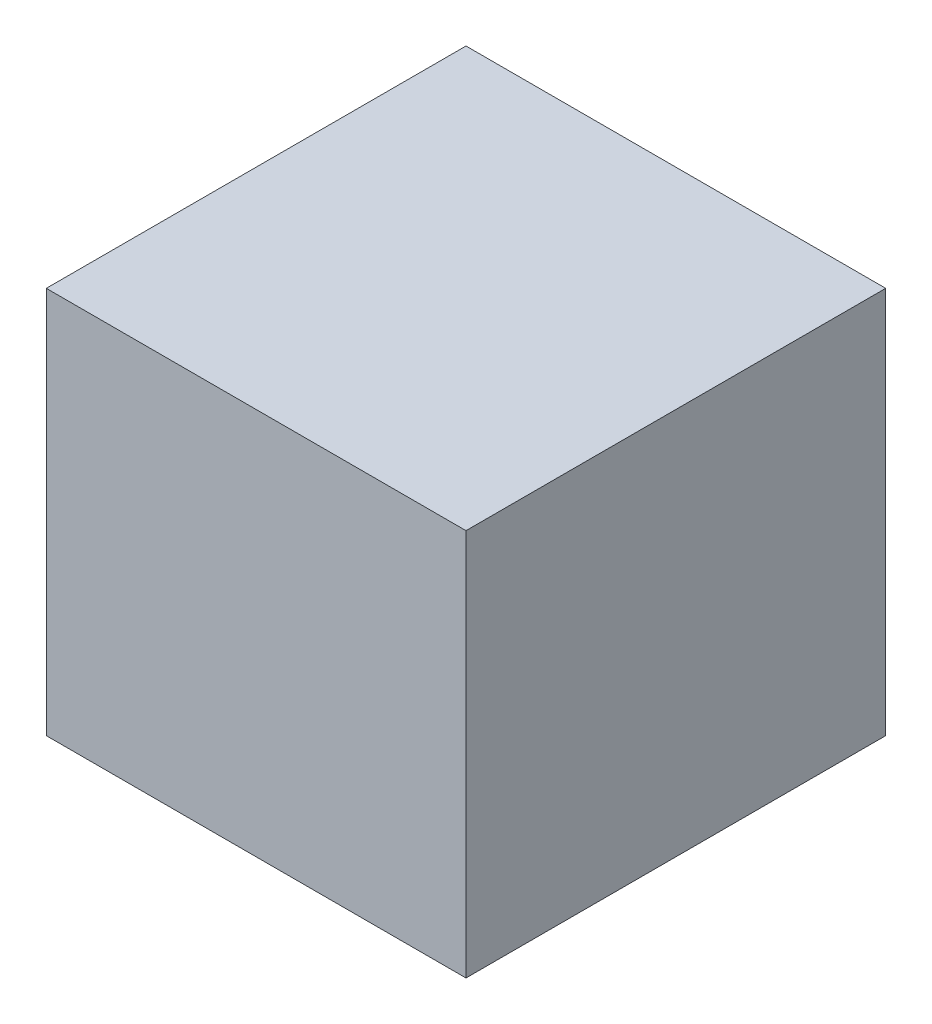
from build123d import *

# Parameters (mm, degrees)
SKETCH_1_W      = 32.5
SKETCH_1_H      = 32.5
EXTRUDE_1_DEPTH = 30


with BuildPart() as part:
    # 草图1 → 凸台-拉伸1 (new body)
    with BuildSketch(Plane(origin=(0, 0, 0), x_dir=(1, 0, 0), z_dir=(0, 1, 0))):
        Rectangle(SKETCH_1_W, SKETCH_1_H)
    extrude(amount=EXTRUDE_1_DEPTH)


solid = part.part
